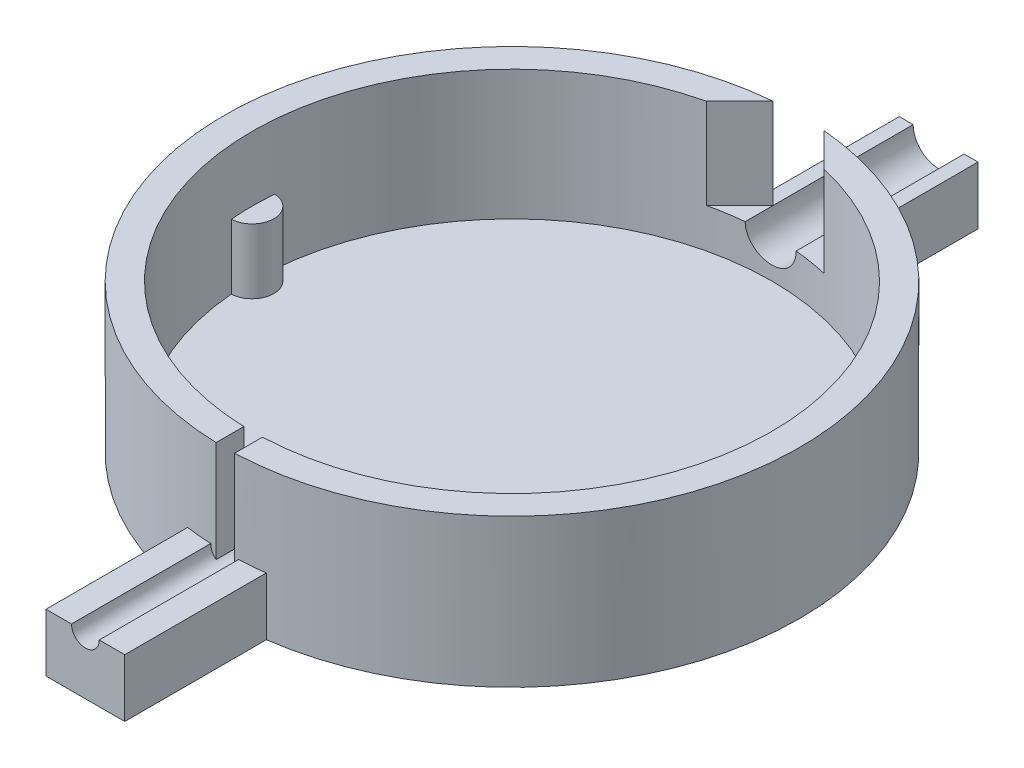
from build123d import *

# Parameters (mm, degrees)
SKETCH1_R           = 31.06
BOSS_EXTRUDE1_DEPTH = 16
SKETCH2_R           = 28.06
CUT_EXTRUDE1_DEPTH  = 14
BOSS_EXTRUDE2_DEPTH = 7
CUT_EXTRUDE2_DEPTH  = 47.748766829
SKETCH5_W           = 2
SKETCH5_H           = 12.000963959
CUT_EXTRUDE3_DEPTH  = 47.748766998
BOSS_EXTRUDE3_DEPTH = 18
BOSS_EXTRUDE4_DEPTH = 18
CUT_EXTRUDE4_DEPTH  = 9.75


with BuildPart() as part:
    # Sketch1 → Boss-Extrude1 (new body)
    with BuildSketch(Plane(origin=(0, 0, 0), x_dir=(1, 0, 0), z_dir=(0, 1, 0))):
        with Locations(Location((0, 0, 0), (0, 0, 270))):
            Circle(SKETCH1_R)
    extrude(amount=BOSS_EXTRUDE1_DEPTH)

    # Sketch2 → Cut-Extrude1 (cut)
    with BuildSketch(Plane(origin=(0, 16, 0), x_dir=(1, 0, 0), z_dir=(0, 1, 0))):
        with Locations(Location((0, 0, 0), (0, 0, 270))):
            Circle(SKETCH2_R)
    extrude(amount=-CUT_EXTRUDE1_DEPTH, mode=Mode.SUBTRACT)

    # Sketch3 → Boss-Extrude2 (add)
    with BuildSketch(Plane(origin=(0, 2, 0), x_dir=(1, 0, 0), z_dir=(0, 1, 0))):
        with BuildLine():
            ThreePointArc((-27.961594797, -2.347938759), (-25.71, 0), (-27.961594797, 2.347938759))
            ThreePointArc((-27.961594797, 2.347938759), (-28.06, 0), (-27.961594797, -2.347938759))
        make_face()
        with BuildLine():
            ThreePointArc((27.961594797, 2.347938759), (25.71, 0), (27.961594797, -2.347938759))
            ThreePointArc((27.961594797, -2.347938759), (28.06, 0), (27.961594797, 2.347938759))
        make_face()
    extrude(amount=BOSS_EXTRUDE2_DEPTH)

    # Sketch4 → Cut-Extrude2 (cut, through all)
    with BuildSketch(Plane.XY):
        with BuildLine():
            Line((2.75, 6.25), (2.75, 16))
            Line((2.75, 16), (-2.75, 16))
            Line((-2.75, 16), (-2.75, 6.25))
            ThreePointArc((-2.75, 6.25), (-1.944543648, 4.305456352), (0, 3.5))
            ThreePointArc((0, 3.5), (1.944543648, 4.305456352), (2.75, 6.25))
        make_face()
    extrude(amount=-CUT_EXTRUDE2_DEPTH, mode=Mode.SUBTRACT)

    # Sketch5 → Cut-Extrude3 (cut, through all)
    with BuildSketch(Plane.XY):
        with Locations((0.098176677, 9.999518021)):
            Rectangle(SKETCH5_W, SKETCH5_H)
    extrude(amount=CUT_EXTRUDE3_DEPTH, mode=Mode.SUBTRACT)

    # Sketch6 → Boss-Extrude3 (add)
    with BuildSketch(Plane.XY.offset(-28.06)):
        with BuildLine():
            Line((-4.25, 0), (4.25, 0))
            Line((4.25, 0), (4.25, 6.25))
            Line((4.25, 6.25), (2.75, 6.25))
            ThreePointArc((2.75, 6.25), (0, 3.5), (-2.75, 6.25))
            Line((-2.75, 6.25), (-4.25, 6.25))
            Line((-4.25, 6.25), (-4.25, 0))
        make_face()
    extrude(amount=-BOSS_EXTRUDE3_DEPTH)

    # Sketch7 → Boss-Extrude4 (add)
    with BuildSketch(Plane(origin=(0, 0, 28.06), x_dir=(-1, 0, 0), z_dir=(0, 0, -1))):
        with BuildLine():
            Line((4.25, 6.25), (1.5, 6.25))
            ThreePointArc((1.5, 6.25), (0, 4.75), (-1.5, 6.25))
            Line((-1.5, 6.25), (-4.25, 6.25))
            Line((-4.25, 6.25), (-4.25, 0))
            Line((-4.25, 0), (4.25, 0))
            Line((4.25, 0), (4.25, 6.25))
        make_face()
    extrude(amount=-BOSS_EXTRUDE4_DEPTH)

    # Sketch8 → Cut-Extrude4 (cut)
    with BuildSketch(Plane(origin=(0, 16, 0), x_dir=(1, 0, 0), z_dir=(0, 1, 0))):
        with BuildLine():
            Line((2.75, 27.924918979), (2.75, 30.938020299))
            Line((2.75, 30.938020299), (6.357775263, 27.330245036))
            ThreePointArc((6.357775263, 27.330245036), (4.563584319, 27.686409991), (2.75, 27.924918979))
        make_face()
        with BuildLine():
            Line((-2.75, 27.924918979), (-2.75, 30.938020299))
            Line((-2.75, 30.938020299), (-6.357775263, 27.330245036))
            ThreePointArc((-6.357775263, 27.330245036), (-4.563584319, 27.686409991), (-2.75, 27.924918979))
        make_face()
    extrude(amount=-CUT_EXTRUDE4_DEPTH, mode=Mode.SUBTRACT)


solid = part.part
